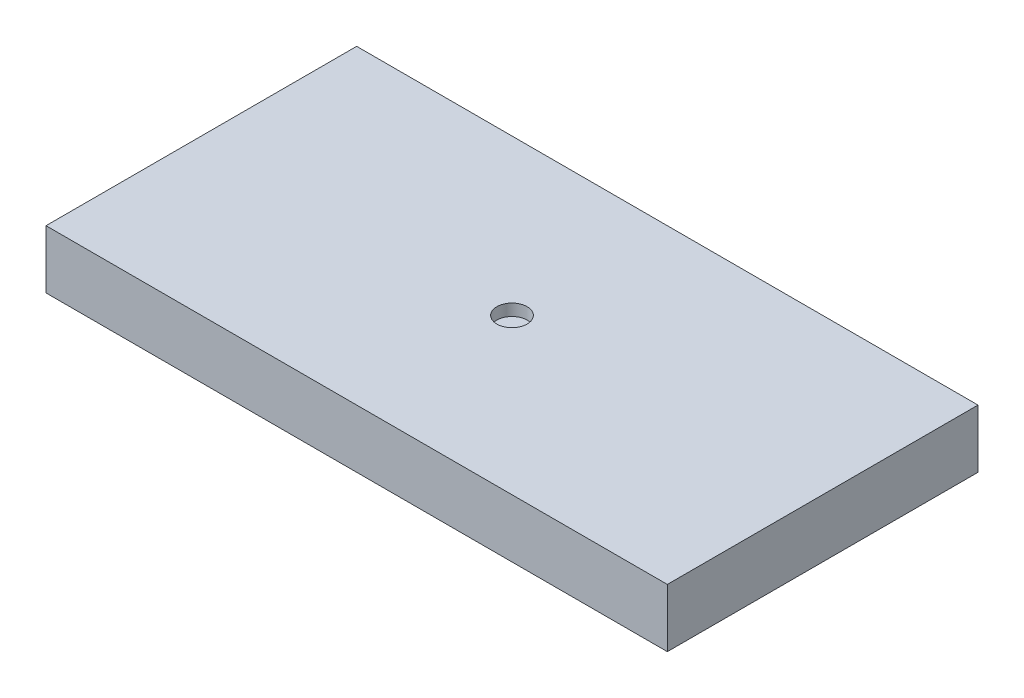
from build123d import *

# Parameters (mm, degrees)
SKETCH1_W           = 40.64
SKETCH1_H           = 20.32
BOSS_EXTRUDE2_DEPTH = 3.81
SKETCH2_R           = 0.988166538
CUT_EXTRUDE1_DEPTH  = 0.762


with BuildPart() as part:
    # Sketch1 → Boss-Extrude2 (new body)
    with BuildSketch(Plane(origin=(0, 0, 0), x_dir=(1, 0, 0), z_dir=(0, 1, 0))):
        Rectangle(SKETCH1_W, SKETCH1_H)
    extrude(amount=BOSS_EXTRUDE2_DEPTH)

    # Sketch2 → Cut-Extrude1 (cut)
    with BuildSketch(Plane(origin=(0, 3.81, 0), x_dir=(1, 0, 0), z_dir=(0, 1, 0))):
        Circle(SKETCH2_R)
    extrude(amount=-CUT_EXTRUDE1_DEPTH, mode=Mode.SUBTRACT)


solid = part.part
